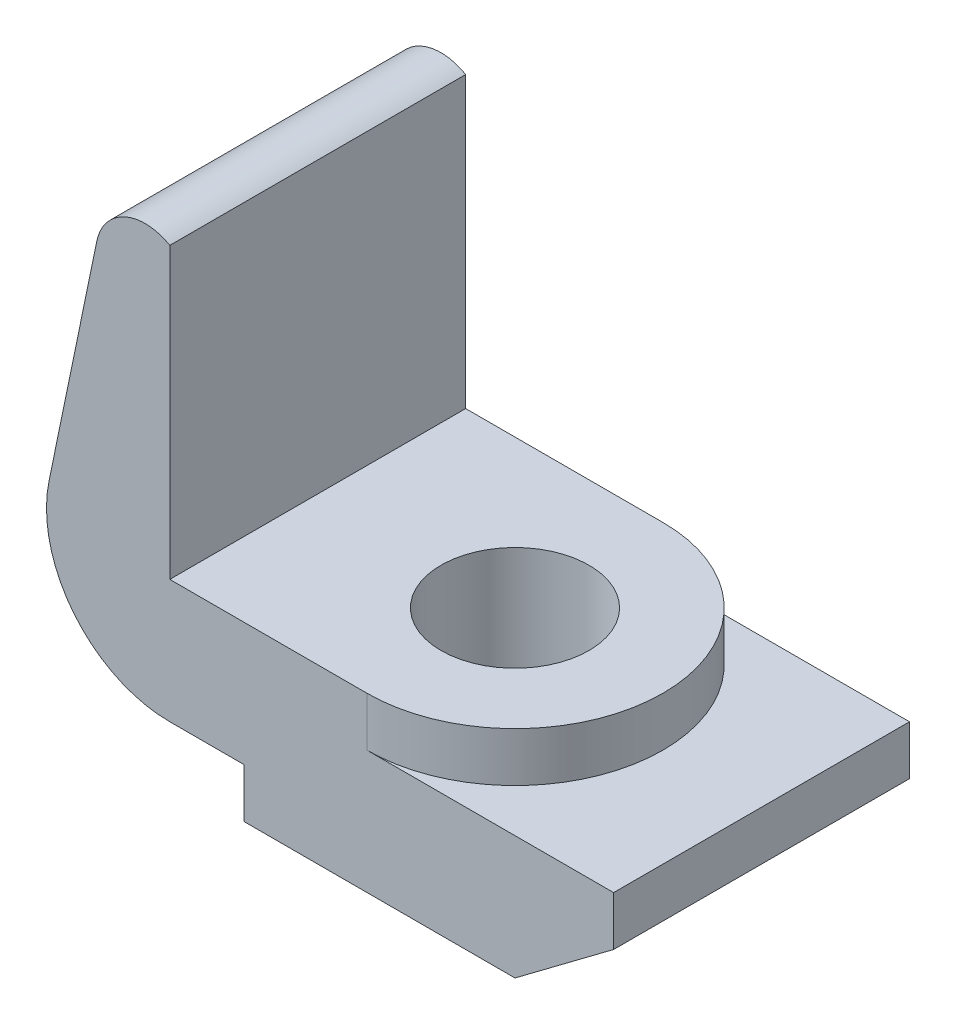
from build123d import *

# Parameters (mm, degrees)
BOSS_EXTRUDE1_DEPTH        = 76.2
SKETCH2_R                  = 38.1
BOSS_EXTRUDE2_DEPTH        = 12.7
F_3_4_1_5_DIAMETER_HOLE1_D = 38.1


with BuildPart() as part:
    # Sketch1 → Boss-Extrude1 (new body)
    with BuildSketch(Plane.XY):
        with BuildLine():
            ThreePointArc((0, 74.498522628), (-11.550198291, 75.086541233), (-18.788031752, 66.066196825))
            Line((-18.788031752, 66.066196825), (-31.095079379, 6.415492062))
            ThreePointArc((-31.095079379, 6.415492062), (-24.614572645, -20.054558422), (0, -31.75))
            Line((0, -31.75), (19.05, -31.75))
            Line((19.05, -31.75), (19.05, -44.45))
            Line((19.05, -44.45), (88.9, -44.45))
            Line((88.9, -44.45), (114.3, -25.4))
            Line((114.3, -25.4), (114.3, -12.7))
            Line((114.3, -12.7), (50.8, -12.7))
            Line((50.8, -12.7), (50.8, 0))
            Line((50.8, 0), (0, 0))
            Line((0, 0), (0, 74.498522628))
        make_face()
    extrude(amount=BOSS_EXTRUDE1_DEPTH)

    # Sketch2 → Boss-Extrude2 (add)
    with BuildSketch(Plane(origin=(0, -12.7, 0), x_dir=(1, 0, 0), z_dir=(0, 1, 0))):
        with Locations((50.8, -38.1)):
            Circle(SKETCH2_R)
    extrude(amount=BOSS_EXTRUDE2_DEPTH)

    # 3/4 (1.5) Diameter Hole1 (through all)
    with Locations(Plane(origin=(0, 0, 0), x_dir=(1, 0, 0), z_dir=(0, 1, 0))):
        with Locations((50.8, -38.1)):
            Hole(F_3_4_1_5_DIAMETER_HOLE1_D / 2)


solid = part.part
